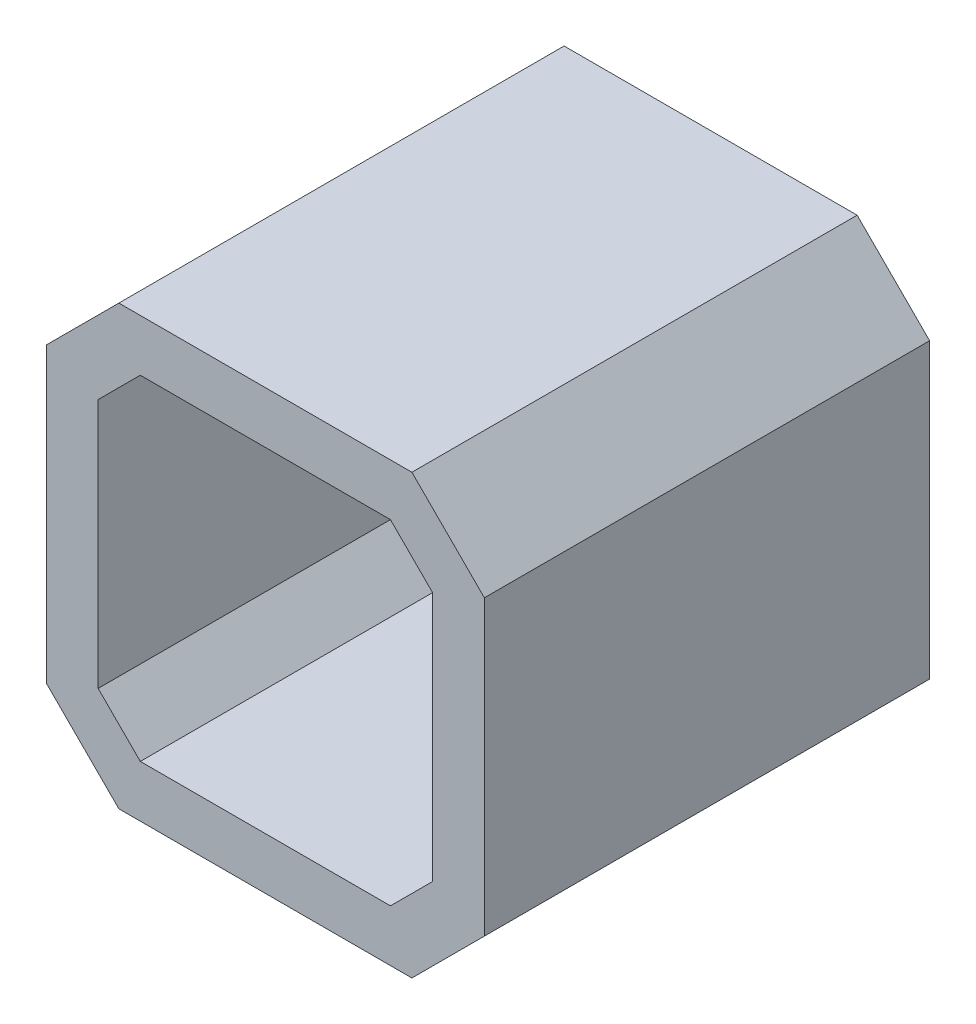
from build123d import *

# Parameters (mm, degrees)
BOSS_EXTRUDE1_DEPTH = 43


with BuildPart() as part:
    # Sketch2 → Boss-Extrude1 (new body)
    with BuildSketch(Plane.XY):
        Polygon((-21.15, 14.15), (-14.15, 21.15), (14.15, 21.15), (21.15, 14.15), (21.15, -14.15), (14.15, -21.15), (-14.15, -21.15), (-21.15, -14.15), align=None)
        Polygon((-12.078932188, 16.15), (12.078932188, 16.15), (16.15, 12.078932188), (16.15, -12.078932188), (12.078932188, -16.15), (-12.078932188, -16.15), (-16.15, -12.078932188), (-16.15, 12.078932188), align=None, mode=Mode.SUBTRACT)
    extrude(amount=BOSS_EXTRUDE1_DEPTH)


solid = part.part
